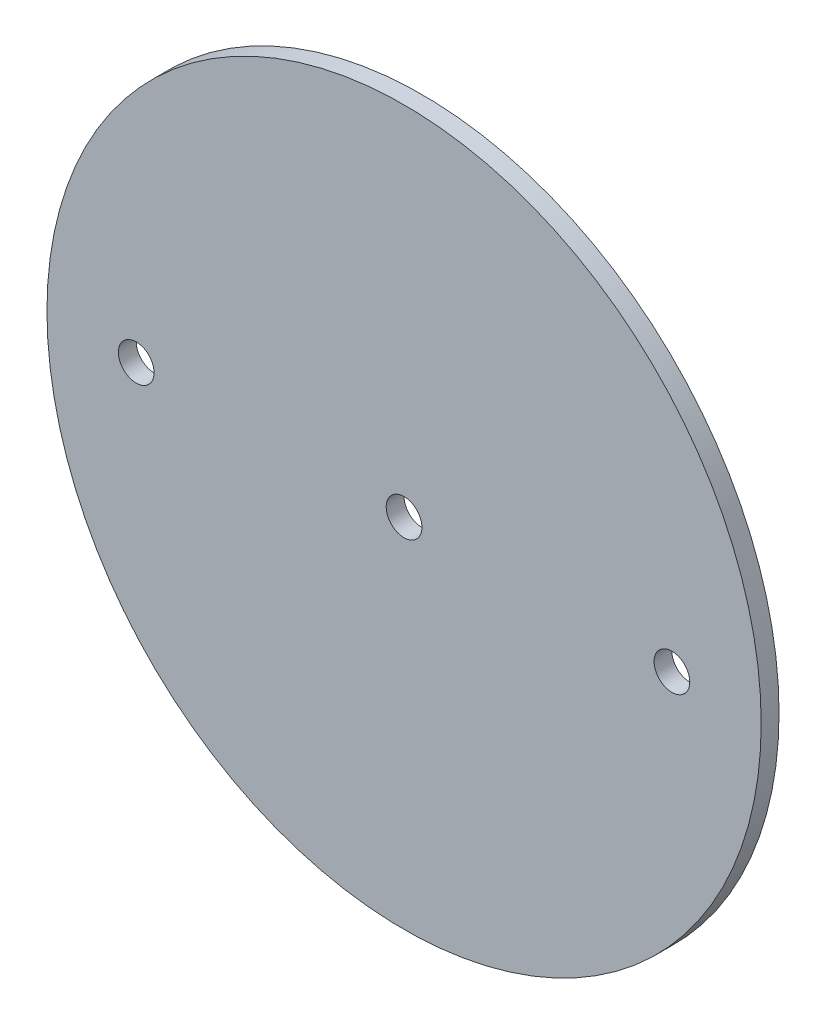
from build123d import *

# Parameters (mm, degrees)
SKETCH1_R                   = 63.5
BOSS_EXTRUDE1_DEPTH         = 1.5875
F_1_4_0_25_DIAMETER_HOLE1_D = 6.35


with BuildPart() as part:
    # Sketch1 → Boss-Extrude1 (new body, symmetric)
    with BuildSketch(Plane.XY):
        Circle(SKETCH1_R)
    extrude(amount=BOSS_EXTRUDE1_DEPTH, both=True)

    # 1/4 (0.25) Diameter Hole1 (through all)
    with Locations(Plane.XY.offset(1.5875)):
        with Locations((-47.625, 0), (0, 0), (47.625, 0)):
            Hole(F_1_4_0_25_DIAMETER_HOLE1_D / 2)


solid = part.part
